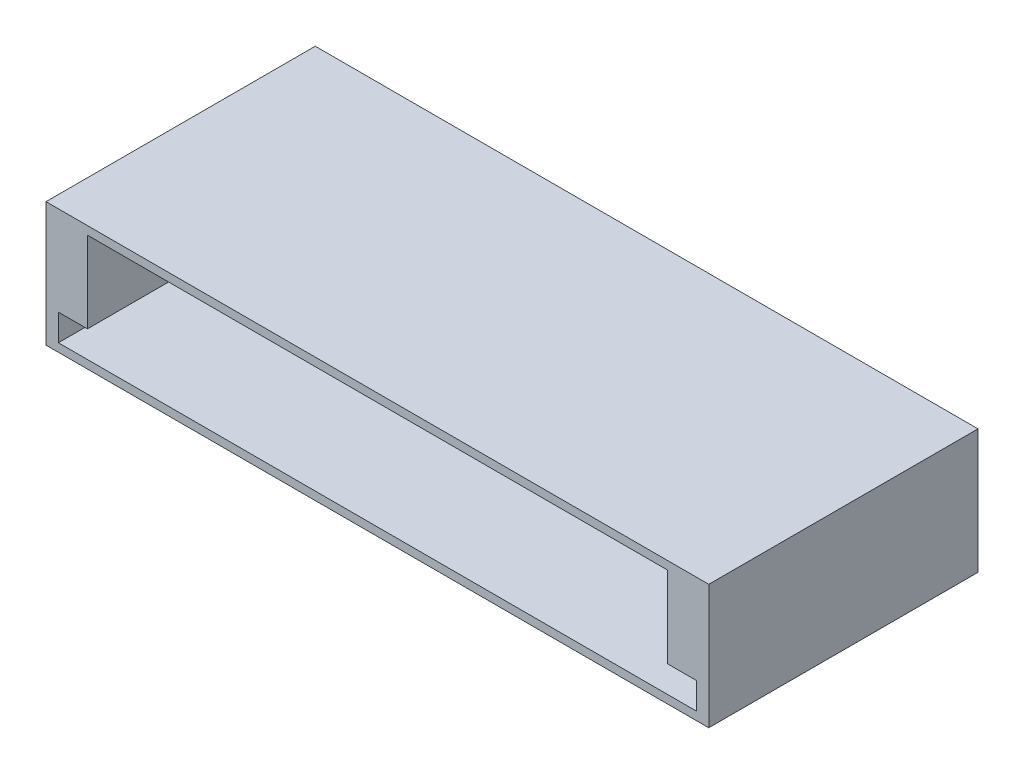
from build123d import *

# Parameters (mm, degrees)
IZIM1_W                     = 80
IZIM1_H                     = 32.5
Y_KSEKLIK_EKSTR_ZYON2_DEPTH = 15
IZIM2_W                     = 70
IZIM2_H                     = 13
KES_EKSTR_ZYON1_DEPTH       = 30
IZIM3_W                     = 77
IZIM3_H                     = 3.2
KES_EKSTR_ZYON3_DEPTH       = 30


with BuildPart() as part:
    # Çizim1 → Yükseklik-Ekstrüzyon2 (new body)
    with BuildSketch(Plane(origin=(0, 0, 0), x_dir=(1, 0, 0), z_dir=(0, 1, 0))):
        with Locations((-14.85188748, -6.644700861)):
            Rectangle(IZIM1_W, IZIM1_H)
    extrude(amount=Y_KSEKLIK_EKSTR_ZYON2_DEPTH)

    # Çizim2 → Kes-Ekstrüzyon1 (cut)
    with BuildSketch(Plane.XY.offset(22.894700861)):
        with Locations((-14.85188748, 7.5)):
            Rectangle(IZIM2_W, IZIM2_H)
    extrude(amount=-KES_EKSTR_ZYON1_DEPTH, mode=Mode.SUBTRACT)

    # Çizim3 → Kes-Ekstrüzyon3 (cut)
    with BuildSketch(Plane.XY.offset(22.894700861)):
        with Locations((-14.85188748, 2.6)):
            Rectangle(IZIM3_W, IZIM3_H)
    extrude(amount=-KES_EKSTR_ZYON3_DEPTH, mode=Mode.SUBTRACT)


solid = part.part
